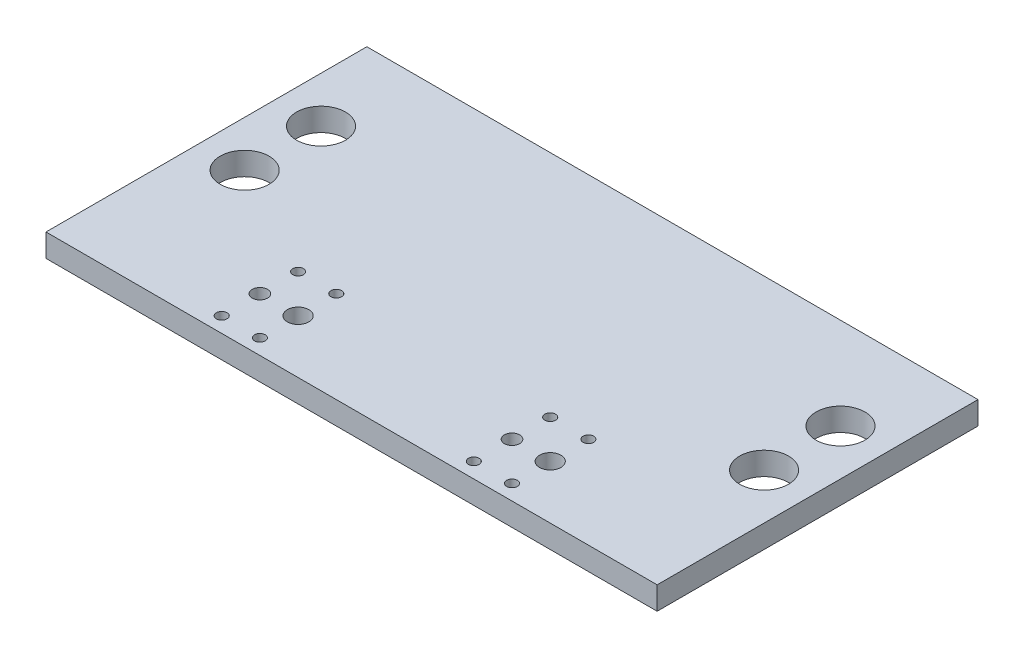
from build123d import *

# Parameters (mm, degrees)
SKETCH_1_W          = 40
SKETCH_1_H          = 21
EXTRUDE_1_DEPTH     = 1.5
SKETCH_2_R          = 0.7
SKETCH_2_R_2        = 0.5
SKETCH_2_R_3        = 0.35
SKETCH_2_R_4        = 1.6
CUT_EXTRUDE_1_DEPTH = 2.5


with BuildPart() as part:
    # Эскиз1 → Бобышка-Вытянуть1 (new body)
    with BuildSketch(Plane(origin=(0, 0, 0), x_dir=(1, 0, 0), z_dir=(0, 1, 0))):
        with Locations((20, 10.5)):
            Rectangle(SKETCH_1_W, SKETCH_1_H)
    extrude(amount=EXTRUDE_1_DEPTH)

    # Эскиз2 → Вырез-Вытянуть1 (cut, through all)
    with BuildSketch(Plane(origin=(0, 1.5, 0), x_dir=(1, 0, 0), z_dir=(0, 1, 0))):
        with Locations((29.5, 3.5)):
            Circle(SKETCH_2_R)
        with Locations((27, 3.5)):
            Circle(SKETCH_2_R_2)
        with Locations((13, 3.5)):
            Circle(SKETCH_2_R)
        with Locations((10.5, 3.5)):
            Circle(SKETCH_2_R_2)
        with Locations((27, 6)):
            Circle(SKETCH_2_R_3)
        with Locations((29.5, 6)):
            Circle(SKETCH_2_R_3)
        with Locations((29.5, 1)):
            Circle(SKETCH_2_R_3)
        with Locations((27, 1)):
            Circle(SKETCH_2_R_3)
        with Locations((13, 6)):
            Circle(SKETCH_2_R_3)
        with Locations((10.5, 6)):
            Circle(SKETCH_2_R_3)
        with Locations((10.5, 1)):
            Circle(SKETCH_2_R_3)
        with Locations((13, 1)):
            Circle(SKETCH_2_R_3)
        with Locations((3, 10)):
            Circle(SKETCH_2_R_4)
        with Locations((37, 10)):
            Circle(SKETCH_2_R_4)
        with Locations((3, 15)):
            Circle(SKETCH_2_R_4)
        with Locations((37, 15)):
            Circle(SKETCH_2_R_4)
    extrude(amount=-CUT_EXTRUDE_1_DEPTH, mode=Mode.SUBTRACT)


solid = part.part
